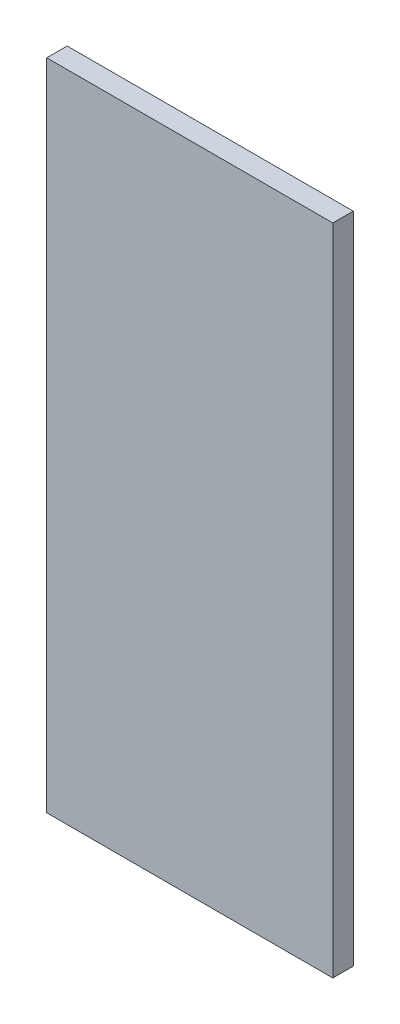
from build123d import *

# Parameters (mm, degrees)
SKETCH1_W           = 88.9
SKETCH1_H           = 6.35
BOSS_EXTRUDE1_DEPTH = 203.2


with BuildPart() as part:
    # Sketch1 → Boss-Extrude1 (new body)
    with BuildSketch(Plane(origin=(0, 0, 0), x_dir=(1, 0, 0), z_dir=(0, 1, 0))):
        with Locations((44.45, 3.175)):
            Rectangle(SKETCH1_W, SKETCH1_H)
    extrude(amount=BOSS_EXTRUDE1_DEPTH)


solid = part.part
